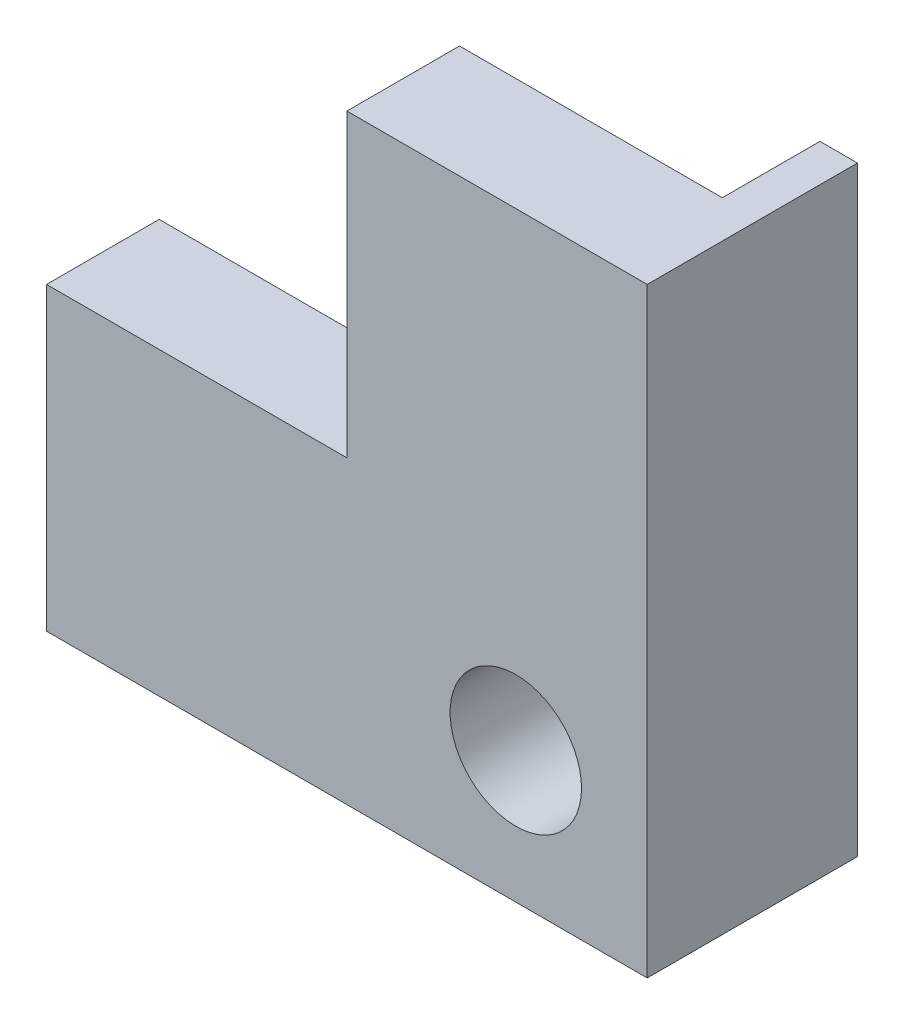
from build123d import *

# Parameters (mm, degrees)
ESQUISSE1_R        = 1.75
BOSS_EXTRU_1_DEPTH = 3
BOSS_EXTRU_2_DEPTH = 5.6
BOSS_EXTRU_3_DEPTH = 1


with BuildPart() as part:
    # Esquisse1 → Boss.-Extru.1 (new body)
    with BuildSketch(Plane.XY):
        Polygon((104.864902494, -135.367060458), (89.864902494, -135.367060458), (89.864902494, -128.367060458), (97.864902494, -128.367060458), (97.864902494, -120.367060458), (104.864902494, -120.367060458), align=None)
        with Locations((102.364902494, -132.867060458)):
            Circle(ESQUISSE1_R, mode=Mode.SUBTRACT)
    extrude(amount=BOSS_EXTRU_1_DEPTH)

    # Esquisse2 → Boss.-Extru.2 (add)
    with BuildSketch(Plane.XY.offset(3)):
        Polygon((89.864902494, -135.367060458), (89.864902494, -136.367060458), (105.864902494, -136.367060458), (105.864902494, -120.367060458), (104.864902494, -120.367060458), (104.864902494, -135.367060458), align=None)
    extrude(amount=-BOSS_EXTRU_2_DEPTH)

    # Esquisse3 → Boss.-Extru.3 (add)
    with BuildSketch(Plane(origin=(0, 0, -2.6), x_dir=(-1, 0, 0), z_dir=(0, 0, -1))):
        with BuildLine():
            Line((-89.864902494, -135.367060458), (-97.364902494, -135.367060458))
            ThreePointArc((-97.364902494, -135.367060458), (-93.614902494, -134.19740032), (-89.864902494, -135.367060458))
        make_face()
        with BuildLine():
            Line((-104.864902494, -127.867060458), (-104.864902494, -120.367060458))
            ThreePointArc((-104.864902494, -120.367060458), (-103.695242356, -124.117060458), (-104.864902494, -127.867060458))
        make_face()
    extrude(amount=-BOSS_EXTRU_3_DEPTH)


solid = part.part
